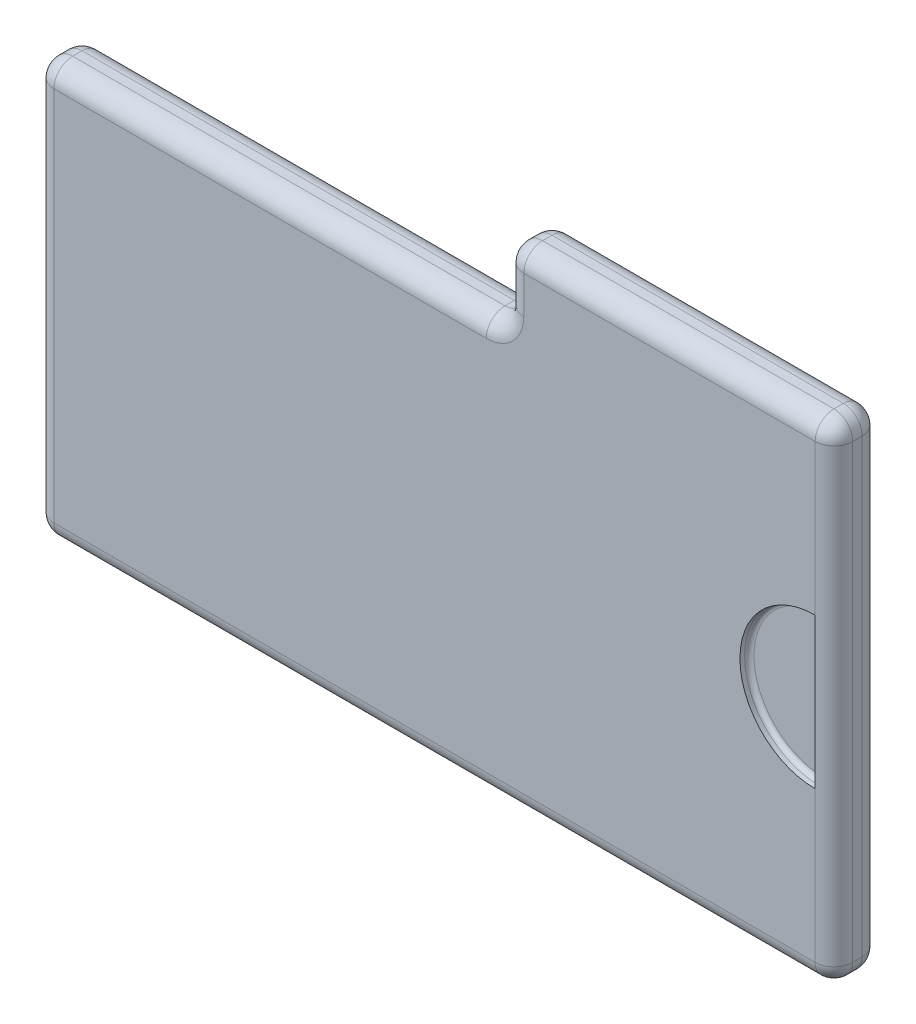
from build123d import *

# Parameters (mm, degrees)
SALIENTE_EXTRUIR1_DEPTH = 2.5
REDONDEO1_R             = 2
CORTAR_EXTRUIR1_DEPTH   = 1
REDONDEO2_R             = 0.5


with BuildPart() as part:
    # Croquis1 → Saliente-Extruir1 (new body, symmetric)
    with BuildSketch(Plane.XY):
        Polygon((7.5, 26), (42.5, 26), (42.5, -26), (-42.5, -26), (-42.5, 18), (-7.5, 18), (7.5, 18), align=None)
    extrude(amount=SALIENTE_EXTRUIR1_DEPTH, both=True)

    # Redondeo1
    redondeo1_edges = [part.edges().sort_by_distance(p)[0] for p in [
        (42.5, 0, -2.5),
        (42.5, -26, 0),
        (-42.5, -26, 0),
        (-42.5, 18, 0),
        (7.5, 22, 2.5),
        (7.5, 18, 0),
        (7.5, 26, 0),
        (42.5, 26, 0),
        (-17.5, 18, 2.5),
        (-42.5, -4, 2.5),
        (0, -26, 2.5),
        (42.5, 0, 2.5),
        (0, -26, -2.5),
        (-42.5, -4, -2.5),
        (-17.5, 18, -2.5),
        (25, 26, 2.5),
        (7.5, 22, -2.5),
        (25, 26, -2.5),
    ]]
    fillet(redondeo1_edges, radius=REDONDEO1_R)

    # Croquis2 → Cortar-Extruir1 (cut)
    with BuildSketch(Plane.XY.offset(2.5)):
        with BuildLine():
            Line((40.5, 8), (40.5, -8))
            ThreePointArc((40.5, -8), (32.5, 0), (40.5, 8))
        make_face()
    extrude(amount=-CORTAR_EXTRUIR1_DEPTH, mode=Mode.SUBTRACT)

    # Redondeo2
    redondeo2_edges = [part.edges().sort_by_distance(p)[0] for p in [
        (32.5, 0, 1.5),
        (40.5, 0, 1.5),
    ]]
    fillet(redondeo2_edges, radius=REDONDEO2_R)


solid = part.part
